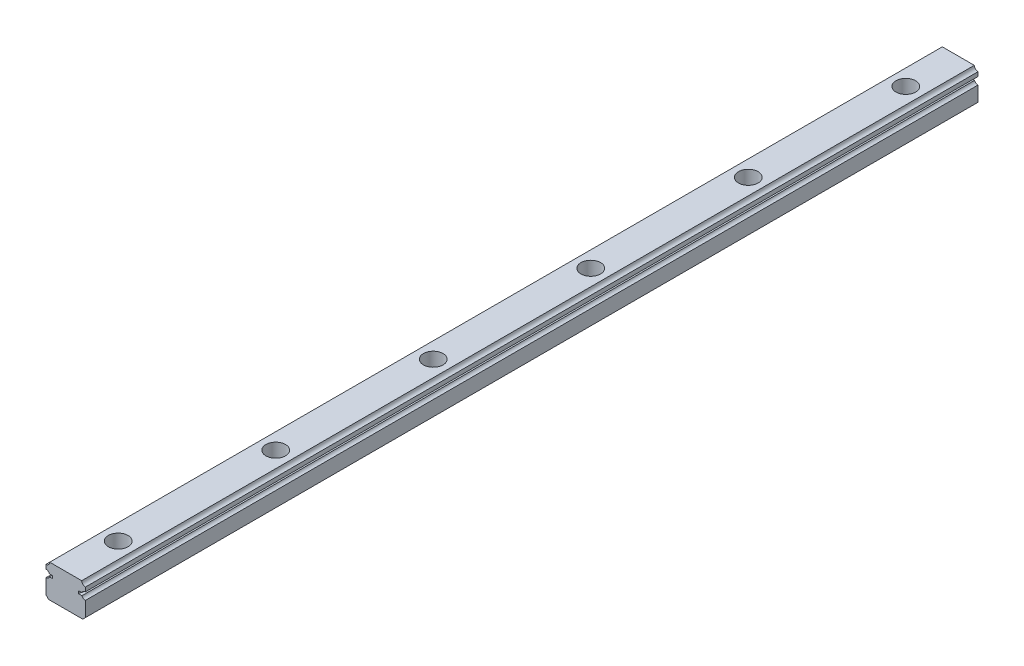
from build123d import *

# Parameters (mm, degrees)
EXTRUDE1_DEPTH  = 170
LPATTERN1_COUNT = 5
LPATTERN1_PITCH = 60


with BuildPart() as part:
    # 15mm → Extrude1 (new, symmetric)
    with BuildSketch(Plane.XY):
        with BuildLine():
            Line((4.949972, 7.600006), (6.192321846, 7.599996))
            ThreePointArc((6.192321846, 7.599996), (6.706266371, 6.946742527), (7.49999, 6.7))
            Line((7.49999, 6.7), (7.49999, 1.000024142))
            Line((7.49999, 1.000024142), (6.499965858, 0))
            Line((6.499965858, 0), (-6.499965858, 0))
            Line((-6.499965858, 0), (-7.49999, 1.000024142))
            Line((-7.49999, 1.000024142), (-7.49999, 6.7))
            ThreePointArc((-7.49999, 6.7), (-6.70626637, 6.946742527), (-6.192321846, 7.599996))
            Line((-6.192321846, 7.599996), (-4.949982, 7.599996))
            Line((-4.949982, 7.599996), (-4.949972, 8.600006))
            Line((-4.949972, 8.600006), (-6.192326435, 8.600016))
            ThreePointArc((-6.192326435, 8.600016), (-6.706271662, 9.253261115), (-7.49999, 9.5))
            Line((-7.49999, 9.5), (-7.49999, 11.099974))
            ThreePointArc((-7.49999, 11.099974), (-6.510037425, 11.510033031), (-6.099989, 12.49999))
            Line((-6.099989, 12.49999), (6.099989, 12.49999))
            ThreePointArc((6.099989, 12.49999), (6.510037425, 11.510033031), (7.49999, 11.099974))
            Line((7.49999, 11.099974), (7.49999, 9.5))
            ThreePointArc((7.49999, 9.5), (6.706271662, 9.253261115), (6.192326435, 8.600016))
            Line((6.192326435, 8.600016), (4.949982, 8.600016))
            Line((4.949982, 8.600016), (4.949972, 7.600006))
        make_face()
    extrude(amount=EXTRUDE1_DEPTH, both=True)

    # Sketch1 → Cut-Revolve1 (revolve, cut)
    with BuildSketch(Plane(origin=(0, 0, 0), x_dir=(0, 0, -1), z_dir=(1, 0, 0))):
        Polygon((-150, 12.49999), (-146.25, 12.49999), (-146.25, 7.19999), (-147.75, 7.19999), (-147.75, 0), (-150, 0), align=None)
    revolve(axis=Axis((0, 0, 150), (0, 1, 0)), mode=Mode.SUBTRACT)

    # Sketch2 → Cut-Revolve2 (revolve, cut)
    with BuildSketch(Plane(origin=(0, 0, 0), x_dir=(0, 0, -1), z_dir=(1, 0, 0))):
        Polygon((150, 0), (152.25, 0), (152.25, 7.19999), (153.75, 7.19999), (153.75, 12.49999), (150, 12.49999), align=None)
    cut_revolve2 = revolve(axis=Axis((0, 12.49999, -150), (0, -1, 0)), mode=Mode.SUBTRACT)

    # LPattern1: Cut-Revolve2 ×5
    with Locations(*[(0, 0, i * LPATTERN1_PITCH) for i in range(1, LPATTERN1_COUNT)]):
        add(cut_revolve2, mode=Mode.SUBTRACT)


solid = part.part
